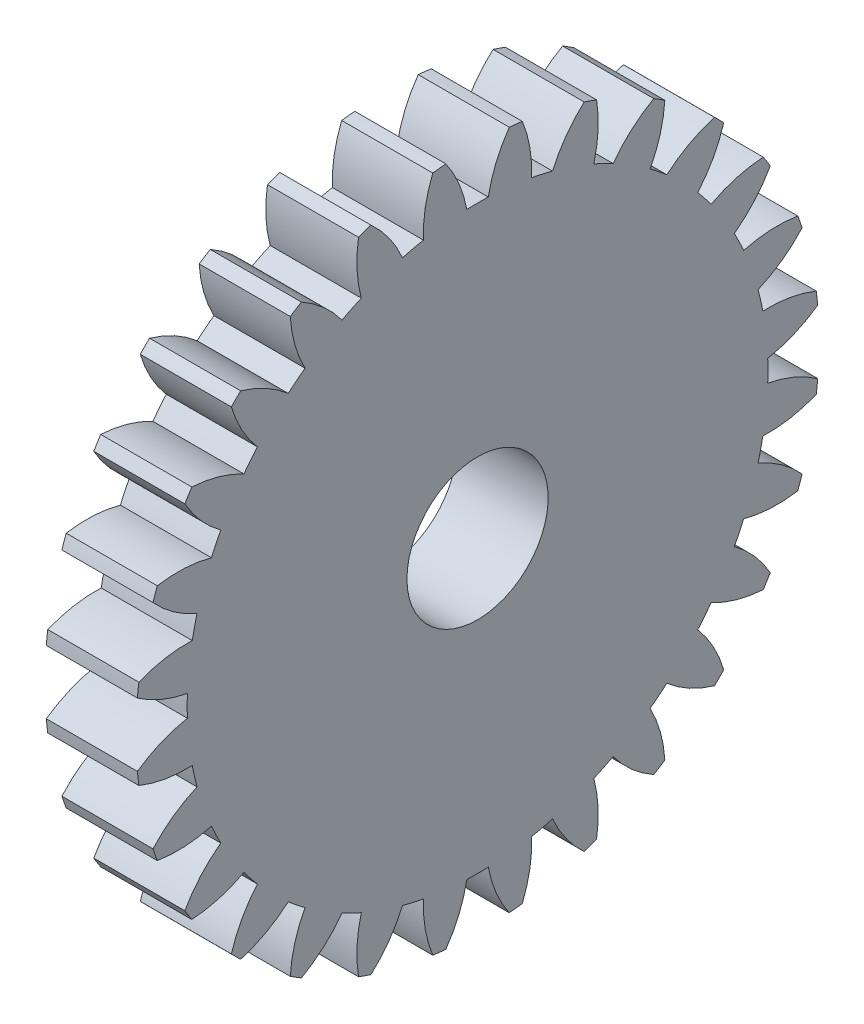
from build123d import *

# Parameters (mm, degrees)
BASPROSKE_W     = 4
BASPROSKE_H     = 15
TOOTHCUT_DEPTH  = 22.587033145
TEETHCUTS_COUNT = 28
TEETHCUTS_ANGLE = 347.142857143
BORSKE_R        = 3.1
BORE_DEPTH      = 50.0000508


with BuildPart() as part:
    # BasProSke → Base-Revolve (revolve)
    with BuildSketch(Plane(origin=(0, 0, 0), x_dir=(1, 0, 0), z_dir=(0, 1, 0)), mode=Mode.PRIVATE) as base_revolve_sk:
        with Locations((2, 7.5)):
            Rectangle(BASPROSKE_W, BASPROSKE_H)
    revolve(base_revolve_sk.sketch.rotate(Axis((-10, 0, 0), (1, 0, 0)), 180), axis=Axis((-10, 0, 0), (1, 0, 0)))

    # TooCutSke → ToothCut (cut, through all)
    with BuildSketch(Plane(origin=(0, 0, 0), x_dir=(0, 0, -1), z_dir=(1, 0, 0))):
        with BuildLine():
            ThreePointArc((0.471336039, 12.740284272), (0, 12.749), (-0.471336039, 12.740284272))
            ThreePointArc((-0.471336039, 12.740284272), (-0.81983923, 13.900763331), (-1.409805137, 14.959114099))
            ThreePointArc((-1.409805137, 14.959114099), (0, 15.0254), (1.409805137, 14.959114099))
            ThreePointArc((1.409805137, 14.959114099), (0.81983923, 13.900763331), (0.471336039, 12.740284272))
        make_face()
    toothcut = extrude(amount=TOOTHCUT_DEPTH, mode=Mode.SUBTRACT)

    # TeethCuts: ToothCut ×28 about axis
    teethcuts_axis = Axis((-10, 0, 0), (1, 0, 0))
    for i in range(1, TEETHCUTS_COUNT):
        add(toothcut.rotate(teethcuts_axis, i * TEETHCUTS_ANGLE / (TEETHCUTS_COUNT - 1)), mode=Mode.SUBTRACT)

    # BorSke → Bore (cut, symmetric)
    with BuildSketch(Plane(origin=(0, 0, 0), x_dir=(0, 0, -1), z_dir=(1, 0, 0))):
        with Locations(Location((0, 0, 0), (0, 0, 180))):
            Circle(BORSKE_R)
    extrude(amount=BORE_DEPTH, both=True, mode=Mode.SUBTRACT)


solid = part.part
